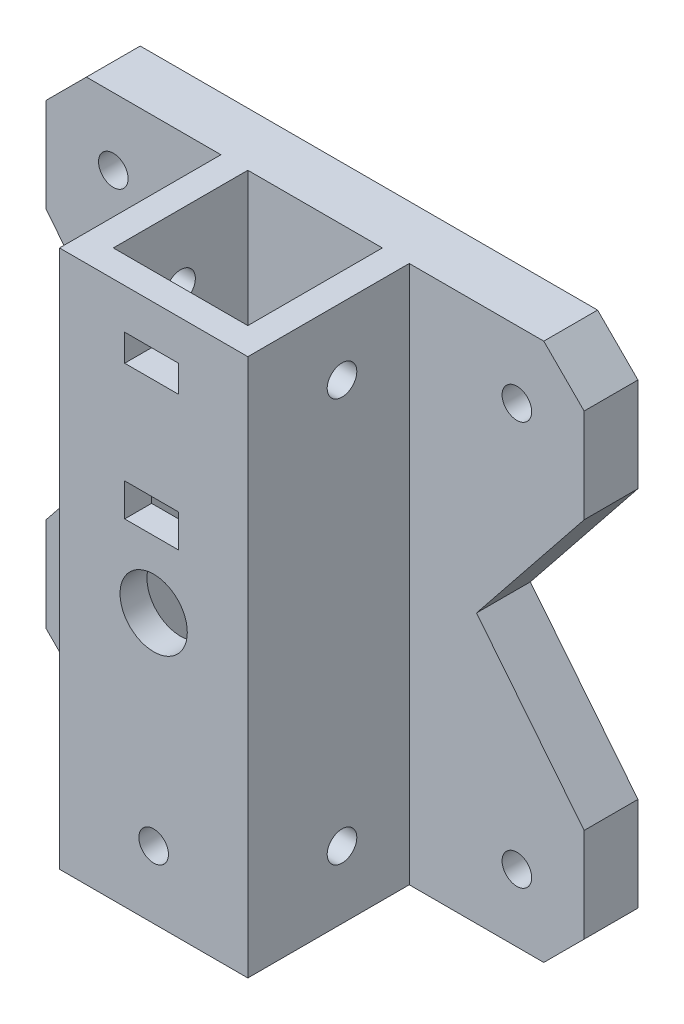
from build123d import *

# Parameters (mm, degrees)
ESQUISSE1_W             = 80
ESQUISSE1_H             = 80
BOSS_EXTRU_1_DEPTH      = 8
ESQUISSE2_W             = 28
ESQUISSE2_H             = 28
ESQUISSE2_W_2           = 20
ESQUISSE2_H_2           = 20
BOSS_EXTRU_2_DEPTH      = 80
D_GAGEMENT_M41_D        = 4.4
D_GAGEMENT_M42_D        = 4.4
D_GAGEMENT_M101_D       = 10
D_GAGEMENT_M101_DEPTH   = 28
D_GAGEMENT_M43_D        = 4.4
D_GAGEMENT_M43_DEPTH    = 5
ESQUISSE13_W            = 8
ESQUISSE13_H            = 4
ESQUISSE13_H_2          = 4.898494306
ENL_V_MAT_EXTRU_1_DEPTH = 4
ENL_V_MAT_EXTRU_2_DEPTH = 9
CHANFREIN2_SIZE         = 6


with BuildPart() as part:
    # Esquisse1 → Boss.-Extru.1 (new body)
    with BuildSketch(Plane.XY):
        Rectangle(ESQUISSE1_W, ESQUISSE1_H)
    extrude(amount=BOSS_EXTRU_1_DEPTH)

    # Esquisse2 → Boss.-Extru.2 (add, through all)
    with BuildSketch(Plane(origin=(0, 40, 0), x_dir=(1, 0, 0), z_dir=(0, 1, 0))):
        with Locations((0, -18)):
            Rectangle(ESQUISSE2_W, ESQUISSE2_H)
        with Locations((0, -18)):
            Rectangle(ESQUISSE2_W_2, ESQUISSE2_H_2, mode=Mode.SUBTRACT)
    extrude(amount=-BOSS_EXTRU_2_DEPTH)

    # Dégagement M41 (through all)
    with Locations(Plane(origin=(0, 0, 0), x_dir=(-1, 0, 0), z_dir=(0, 0, -1))):
        with Locations((-30, 30), (30, 30), (30, -30), (-30, -30), (0, 0)):
            Hole(D_GAGEMENT_M41_D / 2)

    # Dégagement M42 (through all)
    with Locations(Plane(origin=(14, 0, 0), x_dir=(0, 0, -1), z_dir=(1, 0, 0))):
        with Locations((-18, 30), (-18, -30)):
            Hole(D_GAGEMENT_M42_D / 2)

    # Dégagement M101
    with Locations(Plane.XY.offset(32)):
        with Locations((0, 0)):
            Hole(D_GAGEMENT_M101_D / 2, depth=D_GAGEMENT_M101_DEPTH)

    # Dégagement M43
    with Locations(Plane.XY.offset(32)):
        with Locations((0, -30)):
            Hole(D_GAGEMENT_M43_D / 2, depth=D_GAGEMENT_M43_DEPTH)

    # Esquisse13 → Enlèv. mat.-Extru.1 (cut)
    with BuildSketch(Plane.XY.offset(32)):
        with Locations((-0.307514137, 32)):
            Rectangle(ESQUISSE13_W, ESQUISSE13_H)
        with Locations((-0.307514137, 12.405785937)):
            Rectangle(ESQUISSE13_W, ESQUISSE13_H_2)
    extrude(amount=-ENL_V_MAT_EXTRU_1_DEPTH, mode=Mode.SUBTRACT)

    # Esquisse14 → Enlèv. mat.-Extru.2 (cut, through all)
    with BuildSketch(Plane.XY.offset(8)):
        Polygon((-40, 20), (-24, 0), (-40, -20), align=None)
        Polygon((40, 20), (24, 0), (40, -20), align=None)
    extrude(amount=-ENL_V_MAT_EXTRU_2_DEPTH, mode=Mode.SUBTRACT)

    # Chanfrein2
    chanfrein2_edges = [part.edges().sort_by_distance(p)[0] for p in [
        (40, -40, 4),
        (-40, -40, 4),
        (-40, 40, 4),
        (40, 40, 4),
    ]]
    chamfer(chanfrein2_edges, length=CHANFREIN2_SIZE)


solid = part.part
